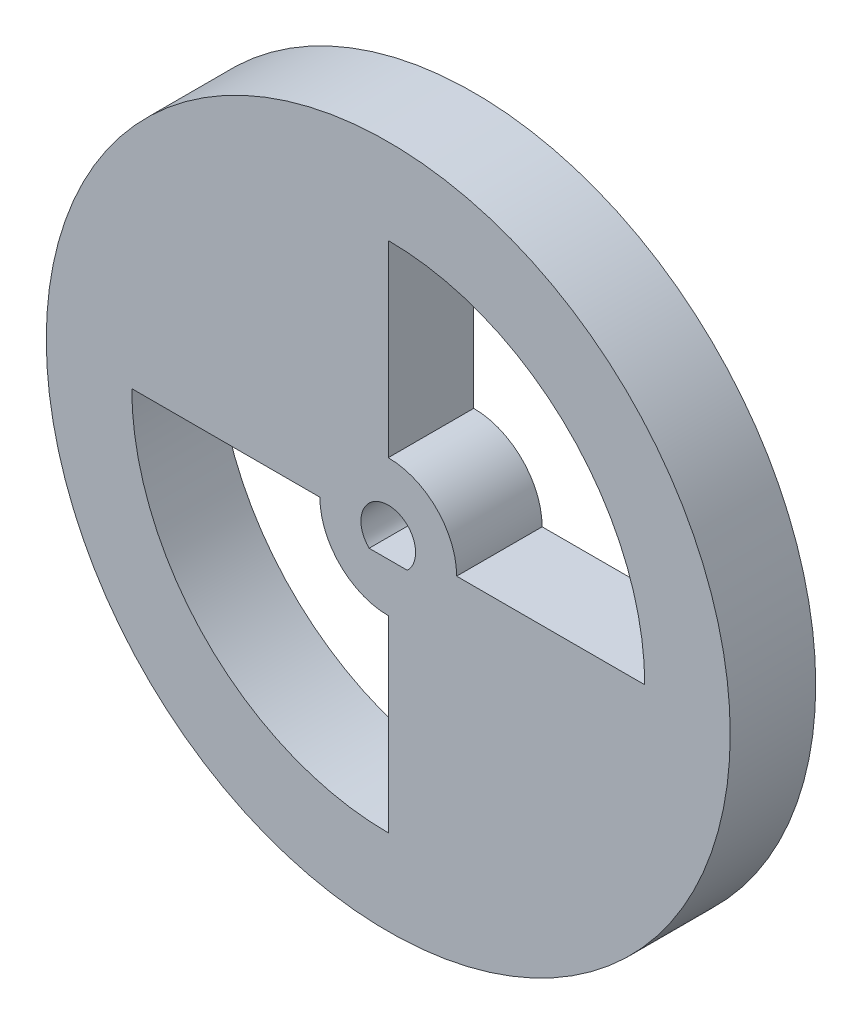
from build123d import *

# Parameters (mm, degrees)
ESBO_O1_R                = 20
RESSALTO_EXTRUS_O1_DEPTH = 4.999999888


with BuildPart() as part:
    # Esboço1 → Ressalto-extrusão1 (new body)
    with BuildSketch(Plane(origin=(0, 0, 0), x_dir=(-1, 0, 0), z_dir=(0, 0, -1))):
        with Locations((48.763208571, 20.144551867)):
            Circle(ESBO_O1_R)
        with BuildLine():
            Line((47.645174582, 18.999999553), (49.881242559, 18.999999553))
            ThreePointArc((49.881242559, 18.999999553), (48.763208571, 21.744551867), (47.645174582, 18.999999553))
        make_face(mode=Mode.SUBTRACT)
        with BuildLine():
            Line((48.763208571, 24.144551867), (48.763208571, 35.144551867))
            ThreePointArc((48.763208571, 35.144551867), (38.156606853, 30.751153585), (33.763208571, 20.144551867))
            Line((33.763208571, 20.144551867), (44.763208571, 20.144551867))
            ThreePointArc((44.763208571, 20.144551867), (45.934781446, 22.972978992), (48.763208571, 24.144551867))
        make_face(mode=Mode.SUBTRACT)
        with BuildLine():
            Line((48.763208571, 5.144551867), (48.763208571, 16.144551867))
            ThreePointArc((48.763208571, 16.144551867), (51.591635695, 17.316124742), (52.763208571, 20.144551867))
            Line((52.763208571, 20.144551867), (63.763208571, 20.144551867))
            ThreePointArc((63.763208571, 20.144551867), (59.369810288, 9.537950149), (48.763208571, 5.144551867))
        make_face(mode=Mode.SUBTRACT)
    extrude(amount=-RESSALTO_EXTRUS_O1_DEPTH)


solid = part.part
